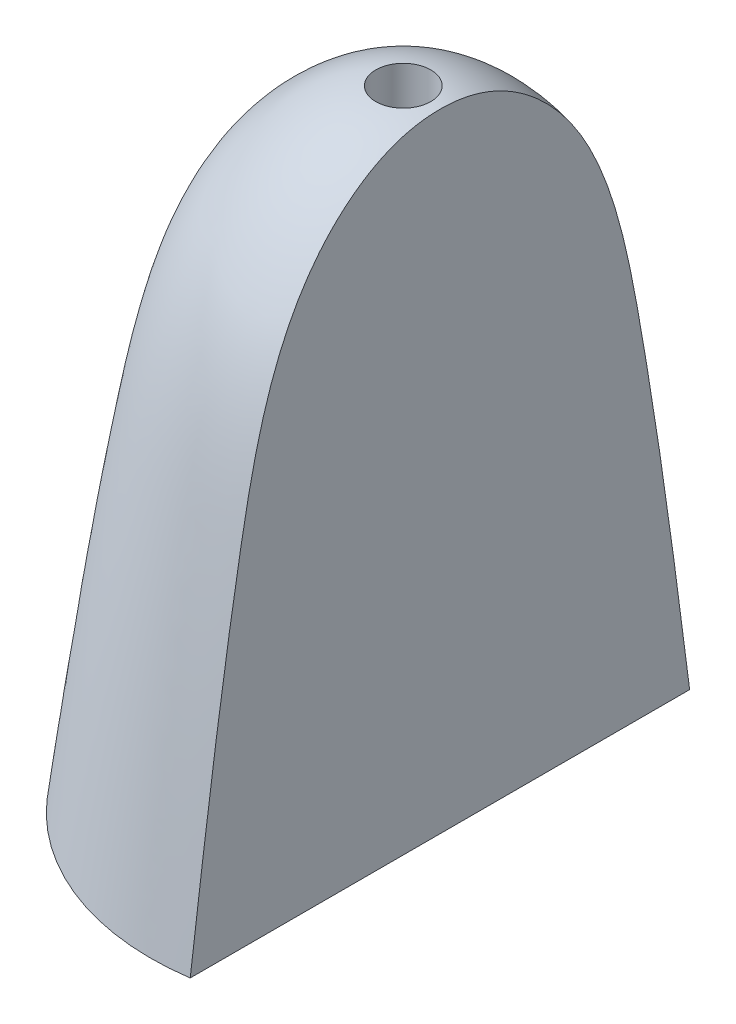
from build123d import *

# Parameters (mm, degrees)
SKETCH2_R                = 0.5
CUT_EXTRUDE2_DEPTH       = 18.207691702
SKETCH5_W                = 5
SKETCH5_H                = 18
CUT_EXTRUDE4_DEPTH       = 20
REVOLVE3_ANGLE           = 90
REVOLVE3_OTHER_WAY_ANGLE = 90
SKETCH12_W               = 15.157920946
SKETCH12_H               = 18.962900337
CUT_EXTRUDE5_DEPTH       = 9
SKETCH14_R               = 0.5
CUT_EXTRUDE6_DEPTH       = 6
SKETCH15_R               = 0.75
CUT_EXTRUDE7_DEPTH       = 7


with BuildPart() as part:
    # Sketch1 → Revolve1 (revolve)
    with BuildSketch(Plane.XY):
        with BuildLine():
            Line((4.88, 0), (6.88, 0))
            add(Edge.make_bspline(
                [(6.88, 0), (6.476901655, 3.177692832), (5.808868292, 8.357754247), (4.378289276, 15.464596201), (1.111060579, 17.280233516), (0, 17.2)],
                knots=[0, 0, 0, 0, 0.473754928, 0.838492431, 1, 1, 1, 1], degree=3))
            Line((0, 17.2), (0, 15.4))
            add(Edge.make_bspline(
                [(0, 15.4), (1.563029619, 15.297760208), (2.284243197, 13.63319745)],
                knots=[0, 0, 0, 1, 1, 1], degree=2))
            add(Edge.make_bspline(
                [(2.284243197, 13.63319745), (4.266259497, 7.778351244), (4.88, 1.606249126)],
                knots=[0, 0, 0, 1, 1, 1], degree=2))
            ThreePointArc((4.88, 1.606249126), (4.905839008, 0.803124563), (4.88, 0))
        make_face()
    revolve(axis=Axis((0, 18.057905706, 0), (0, -1, 0)))

    # Sketch2 → Cut-Extrude2 (cut, through all)
    with BuildSketch(Plane(origin=(0, 0, 0), x_dir=(1, 0, 0), z_dir=(0, 1, 0))):
        Circle(SKETCH2_R)
    extrude(amount=CUT_EXTRUDE2_DEPTH, mode=Mode.SUBTRACT)

    # Sketch5 → Cut-Extrude4 (cut)
    with BuildSketch(Plane.XZ):
        with Locations((4.5, 0.912005105)):
            Rectangle(SKETCH5_W, SKETCH5_H)
    extrude(amount=-CUT_EXTRUDE4_DEPTH, mode=Mode.SUBTRACT)

    # Sketch9 → Revolve3 (revolve)
    with BuildSketch(Plane.XY):
        with BuildLine():
            Line((0, 17.2), (0, 0))
            Line((0, 0), (4.88, 0))
            Line((4.88, 0), (6.88, 0))
            add(Edge.make_bspline(
                [(6.88, 0), (6.476901655, 3.177692832), (5.808868292, 8.357754247), (4.378289276, 15.464596201), (1.111060579, 17.280233516), (0, 17.2)],
                knots=[0, 0, 0, 0, 0.473754928, 0.838492431, 1, 1, 1, 1], degree=3))
        make_face()
    revolve(axis=Axis((0, 17.2, 0), (0, -1, 0)), revolution_arc=REVOLVE3_ANGLE)

    # Sketch9 → Revolve3 other way (revolve)
    with BuildSketch(Plane.XY):
        with BuildLine():
            Line((0, 17.2), (0, 0))
            Line((0, 0), (4.88, 0))
            Line((4.88, 0), (6.88, 0))
            add(Edge.make_bspline(
                [(6.88, 0), (6.476901655, 3.177692832), (5.808868292, 8.357754247), (4.378289276, 15.464596201), (1.111060579, 17.280233516), (0, 17.2)],
                knots=[0, 0, 0, 0, 0.473754928, 0.838492431, 1, 1, 1, 1], degree=3))
        make_face()
    revolve(axis=Axis((0, 17.2, 0), (0, 1, 0)), revolution_arc=REVOLVE3_OTHER_WAY_ANGLE)

    # Sketch12 → Cut-Extrude5 (cut)
    with BuildSketch(Plane(origin=(10, 0, 0), x_dir=(0, 0, -1), z_dir=(1, 0, 0))):
        with Locations((0, 8.631516603)):
            Rectangle(SKETCH12_W, SKETCH12_H)
    extrude(amount=-CUT_EXTRUDE5_DEPTH, mode=Mode.SUBTRACT)

    # Sketch14 → Cut-Extrude6 (cut)
    with BuildSketch(Plane(origin=(0, 20, 0), x_dir=(1, 0, 0), z_dir=(0, 1, 0))):
        Circle(SKETCH14_R)
    extrude(amount=-CUT_EXTRUDE6_DEPTH, mode=Mode.SUBTRACT)

    # Sketch15 → Cut-Extrude7 (cut)
    with BuildSketch(Plane(origin=(0, 20, 0), x_dir=(1, 0, 0), z_dir=(0, 1, 0))):
        Circle(SKETCH15_R)
    extrude(amount=-CUT_EXTRUDE7_DEPTH, mode=Mode.SUBTRACT)


solid = part.part
